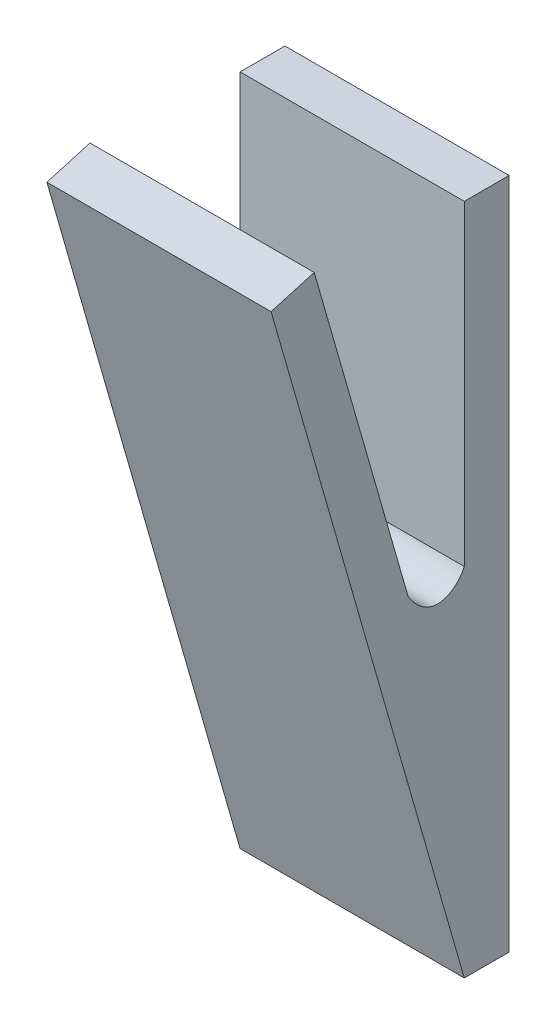
from build123d import *

# Parameters (mm, degrees)
SKETCH1_W           = 10
SKETCH1_H           = 30
BOSS_EXTRUDE1_DEPTH = 2
SKETCH2_W           = 10
SKETCH2_H           = 31.258977403
BOSS_EXTRUDE2_DEPTH = 2
BOSS_EXTRUDE3_DEPTH = 10


with BuildPart() as part:
    # Sketch1 → Boss-Extrude1 (new body)
    with BuildSketch(Plane.XY):
        with Locations((-0.545023697, 5.355450237)):
            Rectangle(SKETCH1_W, SKETCH1_H)
    extrude(amount=BOSS_EXTRUDE1_DEPTH)

    # Sketch2 → Boss-Extrude2 (add)
    with BuildSketch(Plane(origin=(0, -1.262673113, 4.403464453), x_dir=(1, 0, 0), z_dir=(0, -0.275637356, 0.961261696))):
        with Locations((-0.545023697, 6.909827152)):
            Rectangle(SKETCH2_W, SKETCH2_H)
    extrude(amount=-BOSS_EXTRUDE2_DEPTH)

    # Sketch3 → Boss-Extrude3 (add)
    with BuildSketch(Plane.ZY.offset(5.545023697)):
        with BuildLine():
            Line((2, 6.250675975), (2, -2.388639206))
            Line((2, -2.388639206), (4.496805616, 6.318756763))
            add(Edge.make_bspline(
                [(2, 6.250675975), (2.210821092, 5.681941721), (3.390467427, 4.618454358), (4.496805616, 6.318756763)],
                knots=[0, 0, 0, 0, 1, 1, 1, 1], degree=3))
        make_face()
    extrude(amount=-BOSS_EXTRUDE3_DEPTH)


solid = part.part
